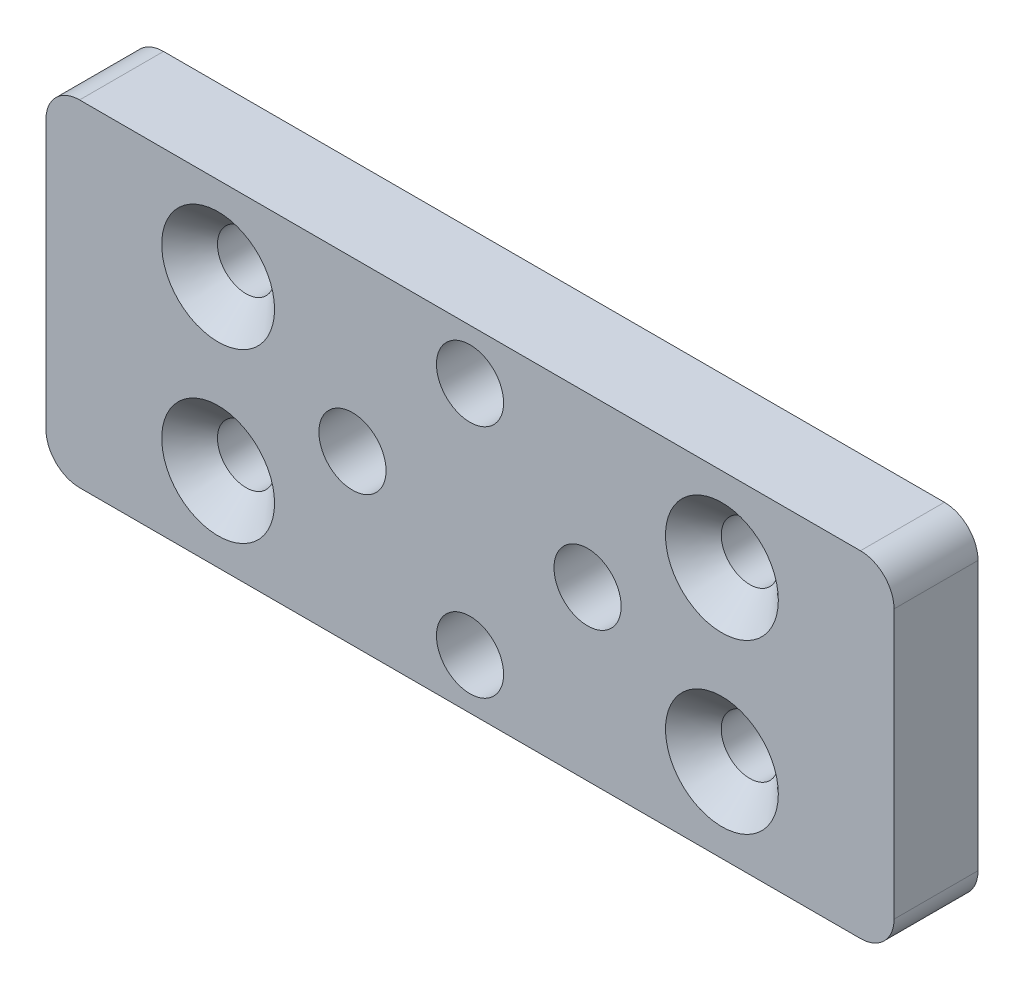
from build123d import *

# Parameters (mm, degrees)
SKETCH_1_W                   = 50.5
SKETCH_1_H                   = 20
EXTRUDE_1_DEPTH              = 5
SKETCH_2_R                   = 1.6
CUT_EXTRUDE_1_DEPTH          = 5
HOLE_WIZARD_M3_1_D           = 3.4
HOLE_WIZARD_M3_1_CSINK_D     = 6.72
HOLE_WIZARD_M3_1_CSINK_ANGLE = 90
SKETCH_6_R                   = 2
CUT_EXTRUDE_2_DEPTH          = 5
FILLET_1_R                   = 2


with BuildPart() as part:
    # 草图1 → 凸台-拉伸1 (new body)
    with BuildSketch(Plane.XY):
        with Locations((25.25, -10)):
            Rectangle(SKETCH_1_W, SKETCH_1_H)
    extrude(amount=EXTRUDE_1_DEPTH)

    # 草图2 → 切除-拉伸1 (cut)
    with BuildSketch(Plane(origin=(0, 0, 0), x_dir=(-1, 0, 0), z_dir=(0, 0, -1))):
        with Locations((-40.25, -5)):
            Circle(SKETCH_2_R)
        with Locations((-40.25, -15)):
            Circle(SKETCH_2_R)
        with Locations((-10.25, -5)):
            Circle(SKETCH_2_R)
        with Locations((-10.25, -15)):
            Circle(SKETCH_2_R)
    extrude(amount=-CUT_EXTRUDE_1_DEPTH, mode=Mode.SUBTRACT)

    # M3 六角凹锥坑螺钉的锥形沉头孔1 (through all)
    with Locations(Plane.XY.offset(5)):
        with Locations((10.25, -5), (10.25, -15), (40.25, -5), (40.25, -15)):
            CounterSinkHole(HOLE_WIZARD_M3_1_D / 2, HOLE_WIZARD_M3_1_CSINK_D / 2, counter_sink_angle=HOLE_WIZARD_M3_1_CSINK_ANGLE)

    # 草图6 → 切除-拉伸2 (cut)
    with BuildSketch(Plane.XY.offset(5)):
        with Locations((25.25, -3)):
            Circle(SKETCH_6_R)
        with Locations((32.25, -10)):
            Circle(SKETCH_6_R)
        with Locations((18.25, -10)):
            Circle(SKETCH_6_R)
        with Locations((25.25, -17)):
            Circle(SKETCH_6_R)
    extrude(amount=-CUT_EXTRUDE_2_DEPTH, mode=Mode.SUBTRACT)

    # 圆角1
    fillet_1_edges = [part.edges().sort_by_distance(p)[0] for p in [
        (0, 0, 2.5),
        (50.5, 0, 2.5),
        (50.5, -20, 2.5),
        (0, -20, 2.5),
    ]]
    fillet(fillet_1_edges, radius=FILLET_1_R)


solid = part.part
